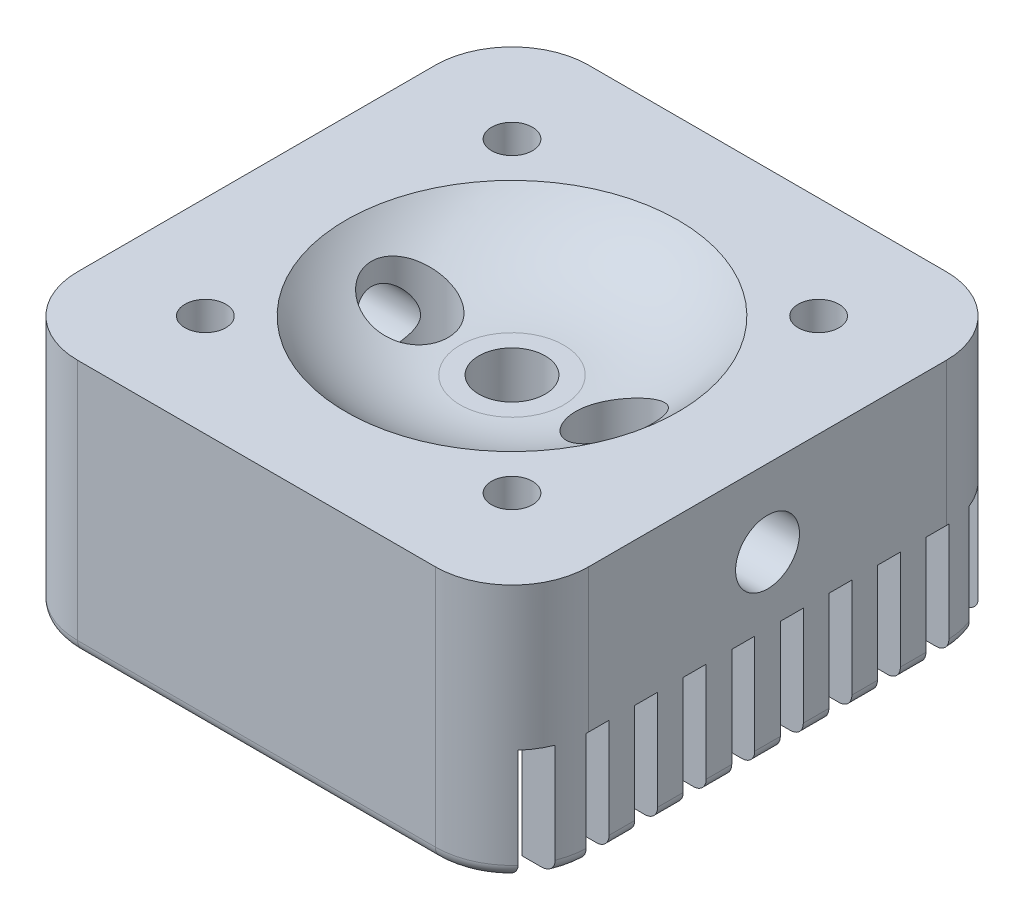
from build123d import *

# Parameters (mm, degrees)
BOSS_EXTRUDE1_DEPTH = 100
CUT_EXTRUDE1_REACH  = 82
SKETCH3_R           = 13
SKETCH6_R           = 15
CUT_EXTRUDE4_DEPTH  = 101
CUT_EXTRUDE5_START  = -51.708438
SKETCH7_R           = 12.5
CUT_EXTRUDE5_DEPTH  = 51.708438
CUT_EXTRUDE9_REACH  = 102
SKETCH12_R          = 8
SKETCH9_W           = 170
SKETCH9_H           = 170
CUT_EXTRUDE6_DEPTH  = 44
FILLET1_R           = 5
SKETCH10_W          = 9
SKETCH10_H          = 44
CUT_EXTRUDE7_DEPTH  = 201.0000001
LPATTERN1_COUNT     = 10
LPATTERN1_PITCH     = 19


with BuildPart() as part:
    # Sketch1 → Boss-Extrude1 (new body)
    with BuildSketch(Plane(origin=(0, 0, 0), x_dir=(1, 0, 0), z_dir=(0, 1, 0))):
        with BuildLine():
            Line((-70, 100), (70, 100))
            ThreePointArc((70, 100), (91.213203436, 91.213203436), (100, 70))
            Line((100, 70), (100, -70))
            ThreePointArc((100, -70), (91.213203436, -91.213203436), (70, -100))
            Line((70, -100), (-70, -100))
            ThreePointArc((-70, -100), (-91.213203436, -91.213203436), (-100, -70))
            Line((-100, -70), (-100, 70))
            ThreePointArc((-100, 70), (-91.213203436, 91.213203436), (-70, 100))
        make_face()
    extrude(amount=BOSS_EXTRUDE1_DEPTH)

    # Sketch2 → Cut-Revolve1 (revolve, cut)
    with BuildSketch(Plane(origin=(0, 0, 0), x_dir=(0, 0, -1), z_dir=(1, 0, 0))):
        with BuildLine():
            Line((0, 80), (20.27864045, 80))
            ThreePointArc((20.27864045, 80), (44.773537878, 85.227744249), (65, 100))
            Line((65, 100), (0, 100))
            Line((0, 100), (0, 80))
        make_face()
    revolve(axis=Axis((0, 0, 0), (0, 1, 0)), mode=Mode.SUBTRACT)

    # Sketch3 → Cut-Extrude1 (cut, up to next)
    with BuildSketch(Plane(origin=(0, 80, 0), x_dir=(1, 0, 0), z_dir=(0, 1, 0)), mode=Mode.PRIVATE) as cut_extrude1_sk1:
        with Locations(Location((0, 0, 0), (0, 0, 270))):  # turned: the seam where the file's is
            Circle(SKETCH3_R)
    cut_extrude1_tool1 = extrude(cut_extrude1_sk1.sketch, amount=-CUT_EXTRUDE1_REACH, mode=Mode.PRIVATE) & part.part
    add(cut_extrude1_tool1.solids().sort_by_distance((0, 80, 0))[0], mode=Mode.SUBTRACT)

    # Sketch6 → Cut-Extrude4 (cut, through all)
    with BuildSketch(Plane(origin=(0, 100, 0), x_dir=(1, 0, 0), z_dir=(0, 1, 0))):
        with Locations(Location((40, 0, 0), (0, 0, 270))):  # turned: the seam where the file's is
            Circle(SKETCH6_R)
        with Locations(Location((-40, 0, 0), (0, 0, 130.759883218))):  # turned: the seam where the file's is
            Circle(SKETCH6_R)
    extrude(amount=-CUT_EXTRUDE4_DEPTH, mode=Mode.SUBTRACT)

    # Sketch7 → Cut-Extrude5 (cut)
    with BuildSketch(Plane.ZY.offset(100).offset(CUT_EXTRUDE5_START)):
        with Locations((0, 70)):
            Circle(SKETCH7_R)
    cut_extrude5 = extrude(amount=CUT_EXTRUDE5_DEPTH, mode=Mode.SUBTRACT)

    # Sketch12 → Cut-Extrude9 (cut, up to next)
    with BuildSketch(Plane(origin=(0, 100, 0), x_dir=(1, 0, 0), z_dir=(0, 1, 0)), mode=Mode.PRIVATE) as cut_extrude9_sk1:
        with Locations(Location((-60, 60, 0), (0, 0, 270))):  # turned: the seam where the file's is
            Circle(SKETCH12_R)
    cut_extrude9_tool1 = extrude(cut_extrude9_sk1.sketch, amount=-CUT_EXTRUDE9_REACH, mode=Mode.PRIVATE) & part.part
    add(cut_extrude9_tool1.solids().sort_by_distance((-60, 100, -60))[0], mode=Mode.SUBTRACT)
    # Sketch12 → Cut-Extrude9 (cut, up to next)
    with BuildSketch(Plane(origin=(0, 100, 0), x_dir=(1, 0, 0), z_dir=(0, 1, 0)), mode=Mode.PRIVATE) as cut_extrude9_sk2:
        with Locations(Location((60, 60, 0), (0, 0, 270))):  # turned: the seam where the file's is
            Circle(SKETCH12_R)
    cut_extrude9_tool2 = extrude(cut_extrude9_sk2.sketch, amount=-CUT_EXTRUDE9_REACH, mode=Mode.PRIVATE) & part.part
    add(cut_extrude9_tool2.solids().sort_by_distance((60, 100, -60))[0], mode=Mode.SUBTRACT)
    # Sketch12 → Cut-Extrude9 (cut, up to next)
    with BuildSketch(Plane(origin=(0, 100, 0), x_dir=(1, 0, 0), z_dir=(0, 1, 0)), mode=Mode.PRIVATE) as cut_extrude9_sk3:
        with Locations(Location((60, -60, 0), (0, 0, 270))):  # turned: the seam where the file's is
            Circle(SKETCH12_R)
    cut_extrude9_tool3 = extrude(cut_extrude9_sk3.sketch, amount=-CUT_EXTRUDE9_REACH, mode=Mode.PRIVATE) & part.part
    add(cut_extrude9_tool3.solids().sort_by_distance((60, 100, 60))[0], mode=Mode.SUBTRACT)
    # Sketch12 → Cut-Extrude9 (cut, up to next)
    with BuildSketch(Plane(origin=(0, 100, 0), x_dir=(1, 0, 0), z_dir=(0, 1, 0)), mode=Mode.PRIVATE) as cut_extrude9_sk4:
        with Locations(Location((-60, -60, 0), (0, 0, 270))):  # turned: the seam where the file's is
            Circle(SKETCH12_R)
    cut_extrude9_tool4 = extrude(cut_extrude9_sk4.sketch, amount=-CUT_EXTRUDE9_REACH, mode=Mode.PRIVATE) & part.part
    add(cut_extrude9_tool4.solids().sort_by_distance((-60, 100, 60))[0], mode=Mode.SUBTRACT)

    # Mirror2: Cut-Extrude5 across plane
    add(cut_extrude5.mirror(Plane(origin=(0, 0, 0), x_dir=(0, 0, 1), z_dir=(1, 0, 0))), mode=Mode.SUBTRACT)

    # Sketch9 → Cut-Extrude6 (cut)
    with BuildSketch(Plane.XZ):
        Rectangle(SKETCH9_W, SKETCH9_H)
    extrude(amount=-CUT_EXTRUDE6_DEPTH, mode=Mode.SUBTRACT)

    # Fillet1
    fillet1_edges = [part.edges().sort_by_distance(p)[0] for p in [
        (0, 0, 100),
        (-91.213203436, 0, 91.213203436),
        (-100, 0, 0),
        (-91.213203436, 0, -91.213203436),
        (0, 0, -100),
        (91.213203436, 0, -91.213203436),
        (100, 0, 0),
        (91.213203436, 0, 91.213203436),
    ]]
    fillet(fillet1_edges, radius=FILLET1_R)

    # Sketch10 → Cut-Extrude7 (cut, through all)
    with BuildSketch(Plane.ZY.offset(100)):
        with Locations((-85.5, 22)):
            Rectangle(SKETCH10_W, SKETCH10_H)
    cut_extrude7 = extrude(amount=-CUT_EXTRUDE7_DEPTH, mode=Mode.SUBTRACT)

    # LPattern1: Cut-Extrude7 ×10
    with Locations(*[(0, 0, i * LPATTERN1_PITCH) for i in range(1, LPATTERN1_COUNT)]):
        add(cut_extrude7, mode=Mode.SUBTRACT)


solid = part.part
